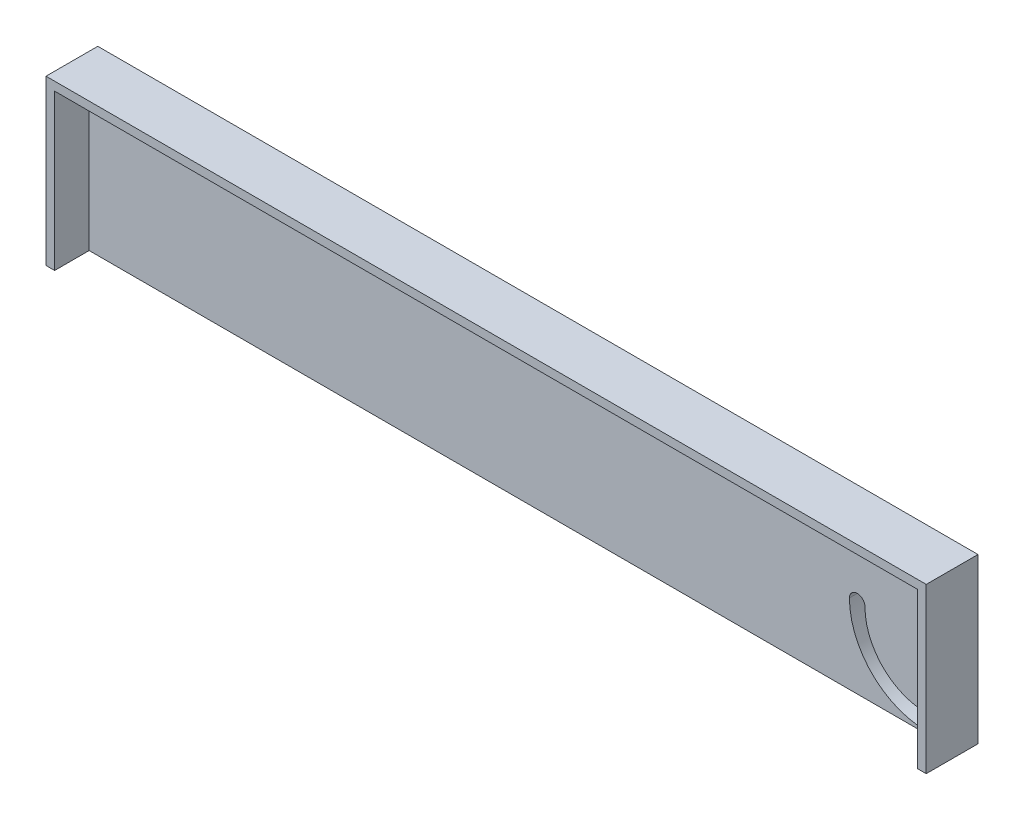
from build123d import *

# Parameters (mm, degrees)
SKETCH1_W           = 510
SKETCH1_H           = 100
SKETCH1_W_2         = 500
SKETCH1_H_2         = 90
BOSS_EXTRUDE1_DEPTH = 20
SKETCH2_W           = 510
SKETCH2_H           = 100
BOSS_EXTRUDE2_DEPTH = 10
SKETCH3_R           = 4.5
CUT_EXTRUDE1_DEPTH  = 1070
SKETCH4_W           = 510
SKETCH4_H           = 5
CUT_EXTRUDE2_DEPTH  = 20


with BuildPart() as part:
    # Sketch1 → Boss-Extrude1 (new body)
    with BuildSketch(Plane.XY):
        with Locations((255, -50)):
            Rectangle(SKETCH1_W, SKETCH1_H)
        with Locations((255, -50)):
            Rectangle(SKETCH1_W_2, SKETCH1_H_2, mode=Mode.SUBTRACT)
    extrude(amount=BOSS_EXTRUDE1_DEPTH)

    # Sketch2 → Boss-Extrude2 (add)
    with BuildSketch(Plane.XY):
        with Locations((255, -50)):
            Rectangle(SKETCH2_W, SKETCH2_H)
    extrude(amount=-BOSS_EXTRUDE2_DEPTH)

    # Sketch3 → Cut-Extrude1 (cut)
    with BuildSketch(Plane.XY):
        with Locations((490, -49)):
            Circle(SKETCH3_R)
        with BuildLine():
            ThreePointArc((445.5, -49), (458.533748237, -80.466251763), (490, -93.5))
            ThreePointArc((490, -93.5), (494.5, -89), (490, -84.5))
            ThreePointArc((490, -84.5), (464.897709268, -74.102290733), (454.5, -49.000000001))
            ThreePointArc((454.5, -49.000000001), (450.000000001, -44.5), (445.5, -49))
        make_face()
    extrude(amount=-CUT_EXTRUDE1_DEPTH, mode=Mode.SUBTRACT)

    # Sketch4 → Cut-Extrude2 (cut, symmetric)
    with BuildSketch(Plane.XY):
        with Locations((255, -97.5)):
            Rectangle(SKETCH4_W, SKETCH4_H)
    extrude(amount=CUT_EXTRUDE2_DEPTH, both=True, mode=Mode.SUBTRACT)


solid = part.part
